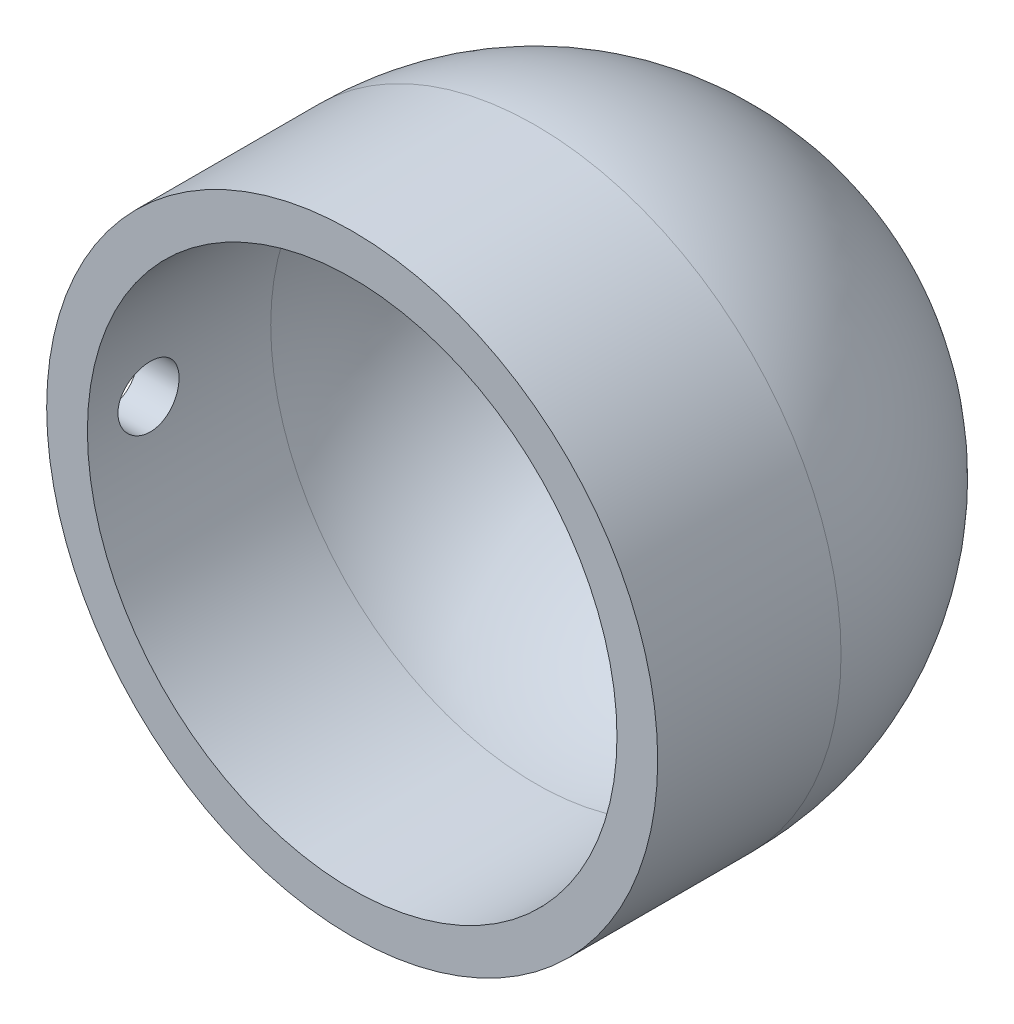
from build123d import *

# Parameters (mm, degrees)
SKETCH4_R          = 1.5
CUT_EXTRUDE1_DEPTH = 10


with BuildPart() as part:
    # Sketch2 one side → Revolve3 (revolve)
    with BuildSketch(Plane(origin=(0, 0, 0), x_dir=(1, 0, 0), z_dir=(0, 1, 0))):
        with BuildLine():
            ThreePointArc((15, 15), (4.393398282, 10.606601718), (0, 0))
            Line((0, 0), (0, -9))
            Line((0, -9), (2, -9))
            Line((2, -9), (2, 0))
            ThreePointArc((2, 0), (5.807611845, 9.192388155), (15, 13))
            Line((15, 13), (15, 15))
        make_face()
    revolve(axis=Axis((15, 0, -26.392000581), (0, 0, 1)))

    # Sketch4 → Cut-Extrude1 (cut)
    with BuildSketch(Plane(origin=(0, 0, 0), x_dir=(0, 0, -1), z_dir=(1, 0, 0))):
        with Locations((-6, 0)):
            Circle(SKETCH4_R)
    extrude(amount=CUT_EXTRUDE1_DEPTH, mode=Mode.SUBTRACT)


solid = part.part
